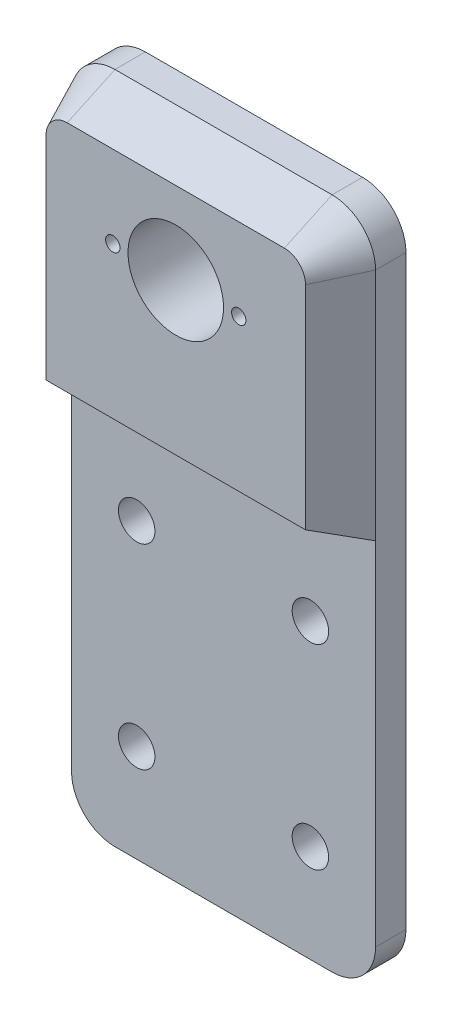
from build123d import *

# Parameters (mm, degrees)
SKETCH1_R           = 4.2
BOSS_EXTRUDE1_DEPTH = 7
BOSS_EXTRUDE2_DEPTH = 11
BOSS_EXTRUDE2_TAPER = 25
SKETCH5_R           = 1.65
SKETCH5_R_2         = 11
CUT_EXTRUDE1_DEPTH  = 19


with BuildPart() as part:
    # Sketch1 → Boss-Extrude1 (new body)
    with BuildSketch(Plane.XY):
        with BuildLine():
            Line((-25, 80), (25, 80))
            ThreePointArc((25, 80), (32.071067812, 77.071067812), (35, 70))
            Line((35, 70), (35, -65))
            ThreePointArc((35, -65), (32.071067812, -72.071067812), (25, -75))
            Line((25, -75), (-25, -75))
            ThreePointArc((-25, -75), (-32.071067812, -72.071067812), (-35, -65))
            Line((-35, -65), (-35, 70))
            ThreePointArc((-35, 70), (-32.071067812, 77.071067812), (-25, 80))
        make_face()
        with Locations((-20, -7.5)):
            Circle(SKETCH1_R, mode=Mode.SUBTRACT)
        with Locations((20, -7.5)):
            Circle(SKETCH1_R, mode=Mode.SUBTRACT)
        with Locations((20, -52.5)):
            Circle(SKETCH1_R, mode=Mode.SUBTRACT)
        with Locations((-20, -52.5)):
            Circle(SKETCH1_R, mode=Mode.SUBTRACT)
    extrude(amount=-BOSS_EXTRUDE1_DEPTH)

    # Sketch3 → Boss-Extrude2 (add)
    with BuildSketch(Plane.XY):
        with BuildLine():
            Line((-35, 16), (35, 16))
            Line((35, 16), (35, 70))
            ThreePointArc((35, 70), (32.071067812, 77.071067812), (25, 80))
            Line((25, 80), (-25, 80))
            ThreePointArc((-25, 80), (-32.071067812, 77.071067812), (-35, 70))
            Line((-35, 70), (-35, 16))
        make_face()
    extrude(amount=BOSS_EXTRUDE2_DEPTH, taper=BOSS_EXTRUDE2_TAPER)

    # Sketch5 → Cut-Extrude1 (cut, through all)
    with BuildSketch(Plane.XY.offset(11)):
        with Locations((-14.5, 56)):
            Circle(SKETCH5_R)
        with Locations((14.5, 56)):
            Circle(SKETCH5_R)
        with Locations((0, 56)):
            Circle(SKETCH5_R_2)
    extrude(amount=-CUT_EXTRUDE1_DEPTH, mode=Mode.SUBTRACT)


solid = part.part
